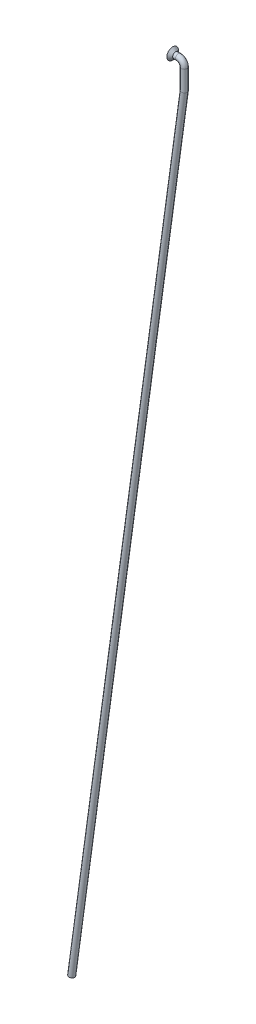
from build123d import *

# Parameters (mm, degrees)
ESQUISSE2_R = 1


with BuildPart() as part:
    # Balayage1: sweep along a path in Esquisse1
    with BuildLine(Plane.XY) as balayage1_path:
        Line((-4, 0), (-2, 0))
        ThreePointArc((-2, 0), (-0.585786438, -0.585786438), (0, -2))
        Line((0, -2), (0, -9))
        Line((0, -9), (-38.776114355, -292.440443433))
    # Esquisse2 → Balayage1 (sweep)
    with BuildSketch(Plane(origin=(-4, 0, 0), x_dir=(0, 0, -1), z_dir=(1, 0, 0))):
        Circle(ESQUISSE2_R)
    sweep(path=balayage1_path.line, transition=Transition.RIGHT)

    # Esquisse3 → Révolution1 (revolve)
    with BuildSketch(Plane.XY):
        Polygon((-4, 1), (-4, 2), (-3, 1), align=None)
    revolve(axis=Axis((0, 0, 0), (-1, 0, 0)))


solid = part.part
